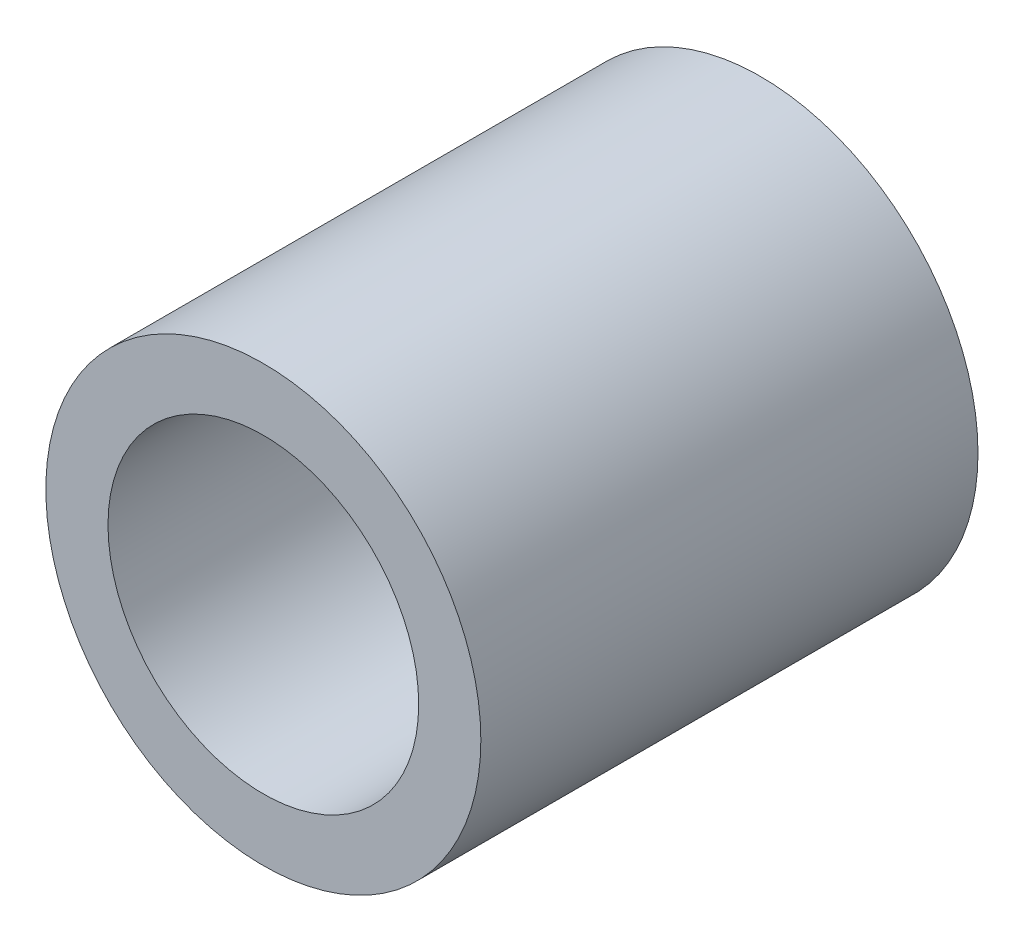
from build123d import *

# Parameters (mm, degrees)
SKETCH1_R           = 8.75
SKETCH1_R_2         = 6.25
EXTRUDE_THIN1_DEPTH = 20


with BuildPart() as part:
    # Sketch1 → Extrude-Thin1 (new body)
    with BuildSketch(Plane.XY):
        Circle(SKETCH1_R)
        Circle(SKETCH1_R_2, mode=Mode.SUBTRACT)
    extrude(amount=EXTRUDE_THIN1_DEPTH)


solid = part.part
